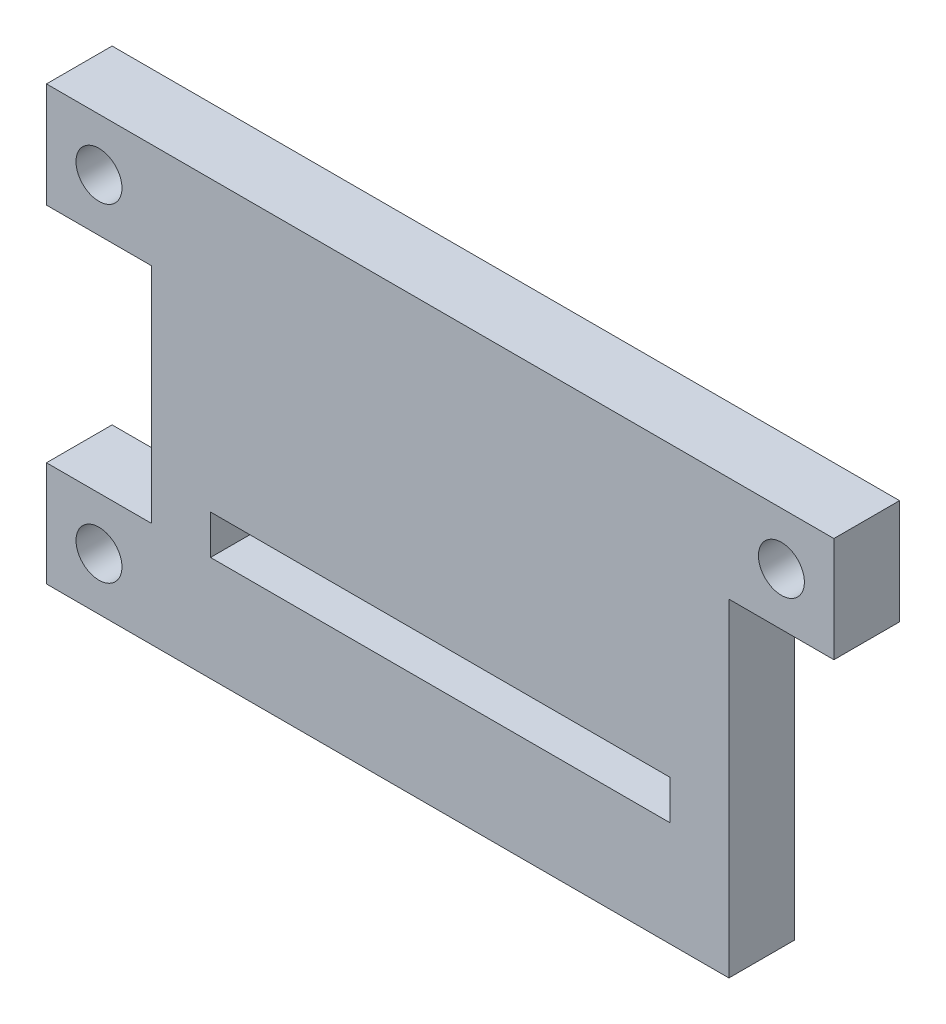
from build123d import *

# Parameters (mm, degrees)
SKETCH_1_R          = 1.75
EXTRUDE_1_DEPTH     = 5
CUT_EXTRUDE_1_REACH = 7
SKETCH_2_W          = 35
SKETCH_2_H          = 3
SKETCH_3_W          = 8
SKETCH_3_H          = 8
CUT_EXTRUDE_3_DEPTH = 6


with BuildPart() as part:
    # 草圖1 → 填料-伸長1 (new body)
    with BuildSketch(Plane.XY):
        Polygon((-30, 16.5), (-30, 8.5), (-22, 8.5), (-22, -8.5), (-30, -8.5), (-30, -16.5), (30, -16.5), (30, -8.5), (22, -8.5), (22, 8.5), (30, 8.5), (30, 16.5), align=None)
        with Locations((-26, 12.5)):
            Circle(SKETCH_1_R, mode=Mode.SUBTRACT)
        with Locations((26, 12.5)):
            Circle(SKETCH_1_R, mode=Mode.SUBTRACT)
        with Locations((-26, -12.5)):
            Circle(SKETCH_1_R, mode=Mode.SUBTRACT)
        with Locations((26, -12.5)):
            Circle(SKETCH_1_R, mode=Mode.SUBTRACT)
    extrude(amount=EXTRUDE_1_DEPTH)

    # 草圖2 → 除料-伸長1 (cut, up to next)
    with BuildSketch(Plane.XY.offset(5), mode=Mode.PRIVATE) as cut_extrude_1_sk1:
        with Locations((0, -7)):
            Rectangle(SKETCH_2_W, SKETCH_2_H)
    cut_extrude_1_tool1 = extrude(cut_extrude_1_sk1.sketch, amount=-CUT_EXTRUDE_1_REACH, mode=Mode.PRIVATE) & part.part
    add(cut_extrude_1_tool1.solids().sort_by_distance((0, -7, 5))[0], mode=Mode.SUBTRACT)

    # 草圖3 → 除料-伸長3 (cut, through all)
    with BuildSketch(Plane.XY):
        with Locations((26, -12.5)):
            Rectangle(SKETCH_3_W, SKETCH_3_H)
    extrude(amount=CUT_EXTRUDE_3_DEPTH, mode=Mode.SUBTRACT)


solid = part.part
